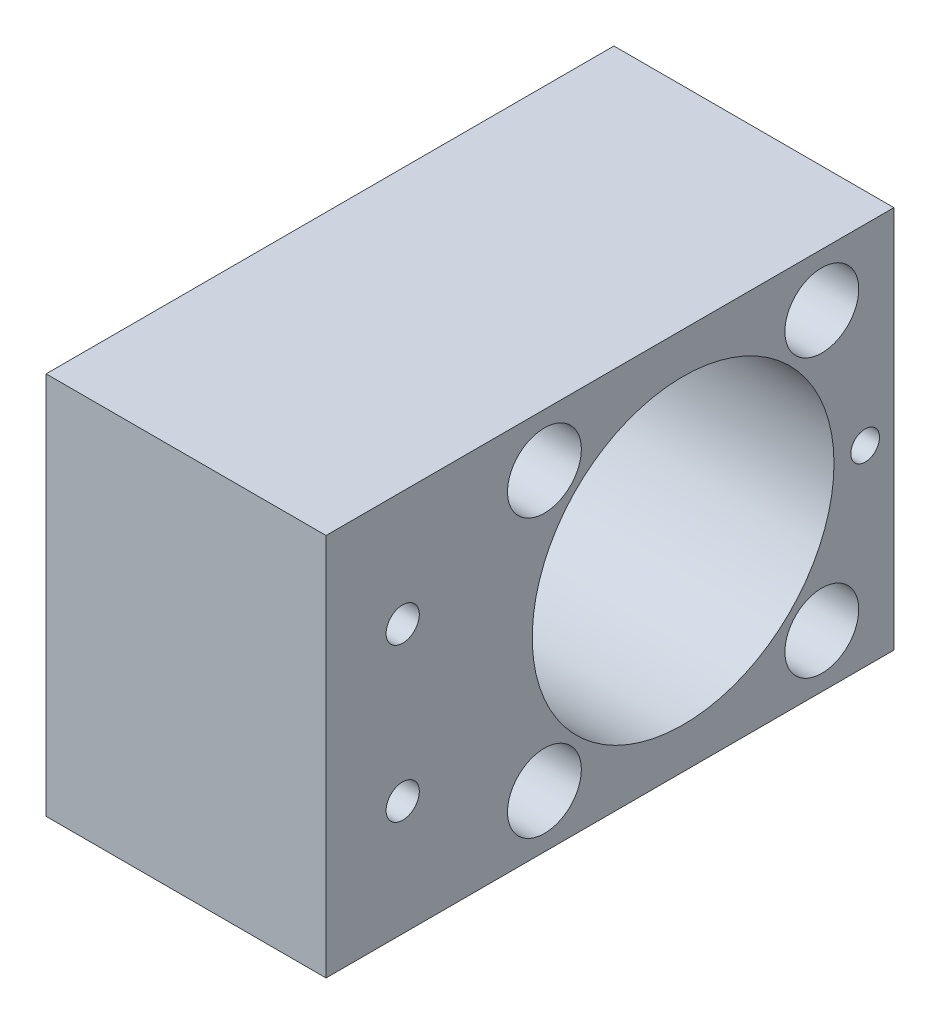
from build123d import *

# Parameters (mm, degrees)
SKETCH1_W                               = 94.087856827
SKETCH1_H                               = 63.5
SKETCH1_R                               = 25
BOSS_EXTRUDE1_DEPTH                     = 46.387125
CBORE_FOR_M5_HEX_HEAD_BOLT1_D           = 5.5
CBORE_FOR_M5_HEX_HEAD_BOLT1_CBORE_D     = 12.24
CBORE_FOR_M5_HEX_HEAD_BOLT1_CBORE_DEPTH = 10
CBORE_FOR_M5_HEX_HEAD_BOLT2_D           = 5.5
CBORE_FOR_M5_HEX_HEAD_BOLT2_CBORE_D     = 12.24
CBORE_FOR_M5_HEX_HEAD_BOLT2_CBORE_DEPTH = 10
HOLE_FOR_6_300_SC_NUTS_SP_1_D           = 4.7625
HOLE_FOR_6_300_SC_NUTS_SP_1_DEPTH       = 12.7
HOLE_FOR_6_300_SC_NUTS_SP_1_TIP         = 1.430799349


with BuildPart() as part:
    # Sketch1 → Boss-Extrude1 (new body)
    with BuildSketch(Plane.ZY.offset(-20.770136657)):
        with Locations((248.31612335, 301.367904211)):
            Rectangle(SKETCH1_W, SKETCH1_H)
        with Locations((236.197194936, 301.367904211)):
            Circle(SKETCH1_R, mode=Mode.SUBTRACT)
    extrude(amount=BOSS_EXTRUDE1_DEPTH)

    # CBORE for M5 Hex Head Bolt1 (through all)
    with Locations(Plane(origin=(20.770136657, 0, 0), x_dir=(0, 0, -1), z_dir=(1, 0, 0))):
        with Locations((-259.178165324, 324.348874599), (-259.178165324, 278.386933822), (-213.216224547, 278.386933822), (-213.216224547, 324.348874599)):
            CounterBoreHole(CBORE_FOR_M5_HEX_HEAD_BOLT1_D / 2, CBORE_FOR_M5_HEX_HEAD_BOLT1_CBORE_D / 2, CBORE_FOR_M5_HEX_HEAD_BOLT1_CBORE_DEPTH)

    # CBORE for M5 Hex Head Bolt2 (through all)
    with Locations(Plane.ZY.offset(25.616988343)):
        with Locations((282.660051763, 314.067904211), (282.660051763, 288.667904211)):
            CounterBoreHole(CBORE_FOR_M5_HEX_HEAD_BOLT2_D / 2, CBORE_FOR_M5_HEX_HEAD_BOLT2_CBORE_D / 2, CBORE_FOR_M5_HEX_HEAD_BOLT2_CBORE_DEPTH)

    # Hole for #6 300® SC Nuts (SP)1
    with Locations(Plane(origin=(20.770136657, 0, 0), x_dir=(0, 0, -1), z_dir=(1, 0, 0))):
        with Locations((-206.034694936, 301.367904211)):
            Hole(HOLE_FOR_6_300_SC_NUTS_SP_1_D / 2, depth=HOLE_FOR_6_300_SC_NUTS_SP_1_DEPTH)
            with Locations((0, 0, -(HOLE_FOR_6_300_SC_NUTS_SP_1_DEPTH + HOLE_FOR_6_300_SC_NUTS_SP_1_TIP / 2))):  # 118° drill point
                Cone(0, HOLE_FOR_6_300_SC_NUTS_SP_1_D / 2, HOLE_FOR_6_300_SC_NUTS_SP_1_TIP, mode=Mode.SUBTRACT)


solid = part.part
